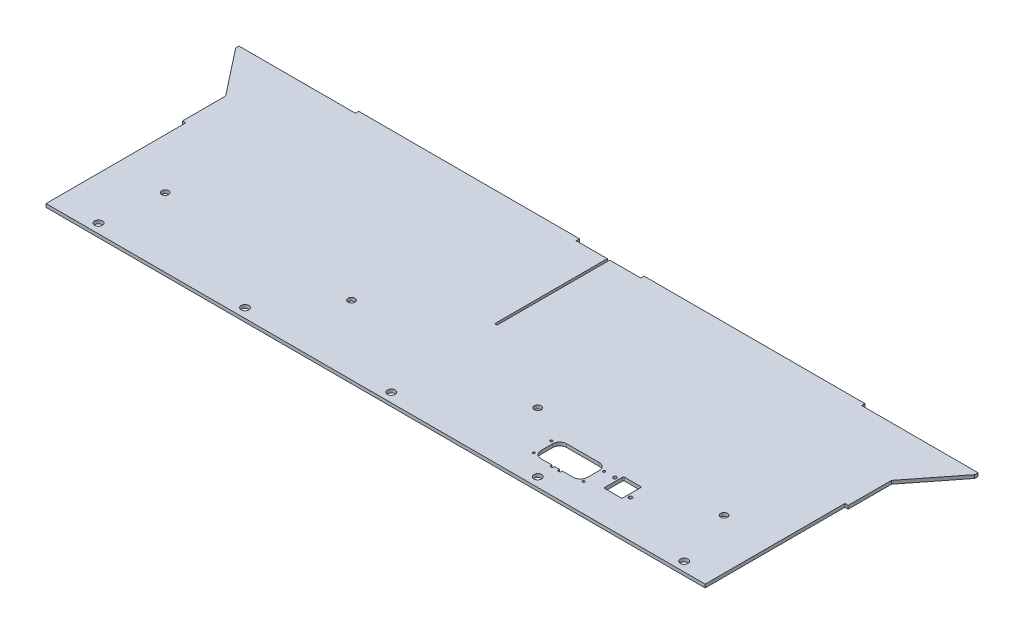
from build123d import *

# Parameters (mm, degrees)
SKETCH1_W            = 635.3556
SKETCH1_H            = 222.25
BOSS_EXTRUDE1_DEPTH  = 1.5875
BOSS_EXTRUDE3_DEPTH  = 3.175
CUT_EXTRUDE1_DEPTH   = 10
LPATTERN1_COUNT      = 5
LPATTERN1_PITCH      = 139.7
SKETCH6_W            = 3.175
SKETCH6_H            = 133.35
SKETCH6_W_2          = 2.286
SKETCH6_H_2          = 107.442
CUT_EXTRUDE2_DEPTH   = 4.175
M6_CLEARANCE_HOLE1_D = 6.6
LPATTERN2_COUNT      = 4
LPATTERN2_PITCH      = 177.8
SKETCH12_W           = 210.6549
SKETCH12_H           = 3.175
BOSS_EXTRUDE4_DEPTH  = 3.175
CUT_EXTRUDE3_DEPTH   = 4.175


with BuildPart() as part:
    # Sketch1 → Boss-Extrude1 (new body, symmetric)
    with BuildSketch(Plane(origin=(0, 0, 0), x_dir=(1, 0, 0), z_dir=(0, 1, 0))):
        Rectangle(SKETCH1_W, SKETCH1_H)
    extrude(amount=BOSS_EXTRUDE1_DEPTH, both=True)

    # Sketch3 → Boss-Extrude3 (add)
    with BuildSketch(Plane(origin=(0, 1.5875, 0), x_dir=(1, 0, 0), z_dir=(0, 1, 0))):
        Polygon((-317.6778, 63.5), (-317.6778, 111.125), (-352.6028, 111.125), (-352.6028, 107.95), align=None)
    boss_extrude3 = extrude(amount=-BOSS_EXTRUDE3_DEPTH)

    # Mirror1: Boss-Extrude3 across plane
    add(boss_extrude3.mirror(Plane(origin=(0, 0, 0), x_dir=(0, 0, 1), z_dir=(1, 0, 0))))

    # Sketch4 → Cut-Extrude1 (cut)
    with BuildSketch(Plane(origin=(0, 1.5875, 0), x_dir=(1, 0, 0), z_dir=(0, 1, 0))):
        with BuildLine():
            ThreePointArc((-276.9028, -102.235), (-275.826417421, -104.833617421), (-273.2278, -105.91))
            Line((-273.2278, -105.91), (-273.2278, -102.235))
            Line((-273.2278, -102.235), (-276.9028, -102.235))
        make_face()
        with BuildLine():
            Line((-273.2278, -102.235), (-273.2278, -105.91))
            ThreePointArc((-273.2278, -105.91), (-270.629182579, -104.833617421), (-269.5528, -102.235))
            ThreePointArc((-269.5528, -102.235), (-273.2278, -98.56), (-276.9028, -102.235))
            Line((-276.9028, -102.235), (-273.2278, -102.235))
        make_face()
    cut_extrude1 = extrude(amount=-CUT_EXTRUDE1_DEPTH, mode=Mode.SUBTRACT)

    # LPattern1: Cut-Extrude1 ×5
    with Locations(*[(i * LPATTERN1_PITCH, 0, 0) for i in range(1, LPATTERN1_COUNT)]):
        add(cut_extrude1, mode=Mode.SUBTRACT)

    # Sketch6 → Cut-Extrude2 (cut, through all)
    with BuildSketch(Plane(origin=(0, 1.5875, 0), x_dir=(1, 0, 0), z_dir=(0, 1, 0))):
        with Locations((316.0903, -44.45)):
            Rectangle(SKETCH6_W, SKETCH6_H)
        with Locations((-316.0903, -44.45)):
            Rectangle(SKETCH6_W, SKETCH6_H)
        with Locations((0, 57.404)):
            Rectangle(SKETCH6_W_2, SKETCH6_H_2)
    extrude(amount=-CUT_EXTRUDE2_DEPTH, mode=Mode.SUBTRACT)

    # M6 Clearance Hole1 (through all)
    with Locations(Plane(origin=(0, 1.5875, 0), x_dir=(1, 0, 0), z_dir=(0, 1, 0))):
        with Locations((266.7, -45.2374)):
            m6_clearance_hole1 = Hole(M6_CLEARANCE_HOLE1_D / 2)

    # LPattern2: M6 Clearance Hole1 ×4
    with Locations(*[(-i * LPATTERN2_PITCH, 0, 0) for i in range(1, LPATTERN2_COUNT)]):
        add(m6_clearance_hole1, mode=Mode.SUBTRACT)

    # Sketch12 → Boss-Extrude4 (add)
    with BuildSketch(Plane(origin=(0, 0, -111.125), x_dir=(-1, 0, 0), z_dir=(0, 0, -1))):
        with Locations((-136.15035, 0)):
            Rectangle(SKETCH12_W, SKETCH12_H)
        with Locations((136.15035, 0)):
            Rectangle(SKETCH12_W, SKETCH12_H)
    extrude(amount=BOSS_EXTRUDE4_DEPTH)

    # Sketch13 → Cut-Extrude3 (cut, through all)
    with BuildSketch(Plane(origin=(0, 1.5875, 0), x_dir=(1, 0, 0), z_dir=(0, 1, 0))):
        with BuildLine():
            add(Edge.make_bspline(
                [(187.864233968, -80.025396339), (189.329368232, -80.025396339), (191.127179802, -77.455295235), (195.339233968, -79.347764363)],
                knots=[1, 1, 1, 1, 3.549888024, 3.549888024, 3.549888024, 3.549888024], degree=3))
            Line((187.864233968, -80.025396339), (194.052572976, -80.025396339))
            add(Edge.make_bspline(
                [(194.052572976, -80.025396339), (194.505115843, -79.75389316), (194.933382129, -79.530112938), (195.339233968, -79.347764363)],
                knots=[-2.795582096, -2.795582096, -2.795582096, -2.795582096, -2.549888024, -2.549888024, -2.549888024, -2.549888024], degree=3))
        make_face()
        with BuildLine():
            add(Edge.make_bspline(
                [(172.699220274, -84.2845266), (172.696730983, -84.975084699), (172.146526339, -85.612330075), (171.260043393, -85.306178116)],
                knots=[0.001799128, 0.001799128, 0.001799128, 0.001799128, 0.583907467, 0.583907467, 0.583907467, 0.583907467], degree=3, weights=[0.996408218, 0.609732375, 0.448956611, 0.514080926]))
            add(Edge.make_bspline(
                [(172.699220274, -84.2845266), (172.233117294, -84.619527082), (171.753512925, -84.960041697), (171.260043393, -85.306178116)],
                knots=[5.458035513, 5.458035513, 5.458035513, 5.458035513, 5.553043212, 5.553043212, 5.553043212, 5.553043212], degree=3))
        make_face()
        with BuildLine():
            add(Edge.make_bspline(
                [(172.699220274, -84.2845266), (172.233117294, -84.619527082), (171.753512925, -84.960041697), (171.260043393, -85.306178116)],
                knots=[5.458035513, 5.458035513, 5.458035513, 5.458035513, 5.553043212, 5.553043212, 5.553043212, 5.553043212], degree=3))
            add(Edge.make_bspline(
                [(172.699227323, -84.280615468), (172.699227323, -84.2819184), (172.699224976, -84.283222113), (172.699220274, -84.2845266)],
                knots=[0, 0, 0, 0, 0.001799128, 0.001799128, 0.001799128, 0.001799128], degree=3, weights=[1, 0.998800581, 0.99760332, 0.996408218]))
            add(Edge.make_bspline(
                [(170.529227323, -84.280615468), (170.529227323, -82.110615468), (172.699227323, -82.110615468), (172.699227323, -84.280615468)],
                knots=[0, 0, 0, 0, 1, 1, 1, 1], degree=3, weights=[1, 0.333333333, 0.333333333, 1]))
            add(Edge.make_bspline(
                [(171.260043393, -85.306178116), (170.752605364, -85.130931488), (170.529227323, -84.697127405), (170.529227323, -84.280615468)],
                knots=[0.583907467, 0.583907467, 0.583907467, 0.583907467, 1, 1, 1, 1], degree=3, weights=[0.514080926, 0.560631953, 0.722604978, 1]))
        make_face()
        with BuildLine():
            add(Edge.make_bspline(
                [(181.739234014, -66.150396507), (181.739234014, -67.664096491), (183.22321105, -68.736498813), (184.551445026, -67.194687875)],
                knots=[0, 0, 0, 0, 0.364606415, 0.364606415, 0.364606415, 0.364606415], degree=3, weights=[1, 0.513858114, 0.382217128, 0.605077042]))
            add(Edge.make_bspline(
                [(182.357862006, -64.886707866), (183.199836269, -65.706024515), (183.926405101, -66.473982103), (184.551445026, -67.194687875)],
                knots=[-3.591687883, -3.591687883, -3.591687883, -3.591687883, -3.27186619, -3.27186619, -3.27186619, -3.27186619], degree=3))
            add(Edge.make_bspline(
                [(182.357862006, -64.886707866), (181.921014319, -65.22596081), (181.739234014, -65.701474289), (181.739234014, -66.150396507)],
                knots=[0.83567377, 0.83567377, 0.83567377, 0.83567377, 1, 1, 1, 1], degree=3, weights=[0.558719959, 0.633805013, 0.78089836, 1]))
        make_face()
        with BuildLine():
            add(Edge.make_bspline(
                [(182.357862006, -64.886707866), (183.199836269, -65.706024515), (183.926405101, -66.473982103), (184.551445026, -67.194687875)],
                knots=[-3.591687883, -3.591687883, -3.591687883, -3.591687883, -3.27186619, -3.27186619, -3.27186619, -3.27186619], degree=3))
            add(Edge.make_bspline(
                [(184.551445026, -67.194687875), (184.825523373, -66.876538362), (184.939234014, -66.502865553), (184.939234014, -66.150396507), (184.939234014, -64.854128029), (183.75318586, -63.803108847), (182.357862006, -64.886707866)],
                knots=[0.364606415, 0.364606415, 0.364606415, 0.364606415, 0.5, 0.5, 0.5, 0.83567377, 0.83567377, 0.83567377, 0.83567377], degree=3, weights=[0.605077042, 0.687834234, 0.81947522, 1, 0.552434973, 0.405341626, 0.558719959]))
        make_face()
        with BuildLine():
            add(Edge.make_bspline(
                [(208.320606163, -76.414085039), (208.757453751, -76.074832094), (208.939234014, -75.599318671), (208.939234014, -75.150396507), (208.939234014, -73.636696641), (207.455257136, -72.564294316), (206.127023101, -74.106105024)],
                knots=[0.335673786, 0.335673786, 0.335673786, 0.335673786, 0.5, 0.5, 0.5, 0.8646064, 0.8646064, 0.8646064, 0.8646064], degree=3, weights=[0.55871998, 0.633805041, 0.780898381, 1, 0.513858133, 0.382217138, 0.605077016]))
            add(Edge.make_bspline(
                [(208.320606163, -76.414085039), (207.478631887, -75.594768389), (206.752063041, -74.826810798), (206.127023101, -74.106105024)],
                knots=[-3.591687913, -3.591687913, -3.591687913, -3.591687913, -3.271866223, -3.271866223, -3.271866223, -3.271866223], degree=3))
        make_face()
        with BuildLine():
            add(Edge.make_bspline(
                [(208.320606163, -76.414085039), (207.478631887, -75.594768389), (206.752063041, -74.826810798), (206.127023101, -74.106105024)],
                knots=[-3.591687913, -3.591687913, -3.591687913, -3.591687913, -3.271866223, -3.271866223, -3.271866223, -3.271866223], degree=3))
            add(Edge.make_bspline(
                [(206.127023101, -74.106105024), (205.852944683, -74.424254558), (205.739234014, -74.797927416), (205.739234014, -75.150396507)],
                knots=[0.8646064, 0.8646064, 0.8646064, 0.8646064, 1, 1, 1, 1], degree=3, weights=[0.605077016, 0.687834206, 0.8194752, 1]))
            add(Edge.make_bspline(
                [(205.739234014, -75.150396507), (205.739234014, -76.446665096), (206.925282318, -77.497684302), (208.320606163, -76.414085039)],
                knots=[0, 0, 0, 0, 0.335673786, 0.335673786, 0.335673786, 0.335673786], degree=3, weights=[1, 0.552434953, 0.405341613, 0.55871998]))
        make_face()
        with BuildLine():
            add(Edge.make_bspline(
                [(186.714233968, -78.875396339), (186.714233968, -79.019043261), (186.763644326, -79.299941363), (187.025758436, -79.71387187), (187.439688944, -79.975985981), (187.720587046, -80.025396339), (187.864233968, -80.025396339)],
                knots=[0, 0, 0, 0, 0.25, 0.5, 0.75, 1, 1, 1, 1], degree=3))
            add(Edge.make_bspline(
                [(187.864233968, -80.025396339), (189.329368232, -80.025396339), (191.127179802, -77.455295235), (195.339233968, -79.347764363)],
                knots=[1, 1, 1, 1, 3.549888024, 3.549888024, 3.549888024, 3.549888024], degree=3))
            add(Edge.make_bspline(
                [(195.339233968, -79.347764363), (199.551288134, -77.455295235), (201.349099704, -80.025396339), (202.814233968, -80.025396339)],
                knots=[-2.549888024, -2.549888024, -2.549888024, -2.549888024, 0, 0, 0, 0], degree=3))
            add(Edge.make_bspline(
                [(202.814233968, -80.025396339), (202.95788089, -80.025396339), (203.238778991, -79.975985981), (203.652709499, -79.71387187), (203.914823609, -79.299941363), (203.964233968, -79.019043261), (203.964233968, -78.875396339)],
                knots=[0, 0, 0, 0, 0.25, 0.5, 0.75, 1, 1, 1, 1], degree=3))
            add(Edge.make_bspline(
                [(203.964233968, -78.875396339), (203.964233968, -77.326116927), (201.0904451, -75.40485046), (203.658155381, -70.650396339)],
                knots=[1, 1, 1, 1, 3.696332423, 3.696332423, 3.696332423, 3.696332423], degree=3))
            add(Edge.make_bspline(
                [(203.658155381, -70.650396339), (201.0904451, -65.895942219), (203.964233968, -63.974675752), (203.964233968, -62.425396339)],
                knots=[-2.696332423, -2.696332423, -2.696332423, -2.696332423, 0, 0, 0, 0], degree=3))
            add(Edge.make_bspline(
                [(203.964233968, -62.425396339), (203.964233968, -62.281749417), (203.914823609, -62.000851316), (203.652709499, -61.586920808), (203.238778991, -61.324806697), (202.95788089, -61.275396339), (202.814233968, -61.275396339)],
                knots=[0, 0, 0, 0, 0.25, 0.5, 0.75, 1, 1, 1, 1], degree=3))
            add(Edge.make_bspline(
                [(202.814233968, -61.275396339), (201.349099704, -61.275396339), (199.551288134, -63.845497444), (195.339233968, -61.953028316)],
                knots=[1, 1, 1, 1, 3.549888024, 3.549888024, 3.549888024, 3.549888024], degree=3))
            add(Edge.make_bspline(
                [(195.339233968, -61.953028316), (191.127179802, -63.845497444), (189.329368232, -61.275396339), (187.864233968, -61.275396339)],
                knots=[-2.549888024, -2.549888024, -2.549888024, -2.549888024, 0, 0, 0, 0], degree=3))
            add(Edge.make_bspline(
                [(187.864233968, -61.275396339), (187.720587046, -61.275396339), (187.439688944, -61.324806697), (187.025758436, -61.586920808), (186.763644326, -62.000851316), (186.714233968, -62.281749417), (186.714233968, -62.425396339)],
                knots=[0, 0, 0, 0, 0.25, 0.5, 0.75, 1, 1, 1, 1], degree=3))
            add(Edge.make_bspline(
                [(186.714233968, -62.425396339), (186.714233968, -63.974675752), (189.588022835, -65.895942219), (187.020312555, -70.650396339)],
                knots=[1, 1, 1, 1, 3.696332423, 3.696332423, 3.696332423, 3.696332423], degree=3))
            add(Edge.make_bspline(
                [(187.020312555, -70.650396339), (189.588022835, -75.40485046), (186.714233968, -77.326116927), (186.714233968, -78.875396339)],
                knots=[-2.696332423, -2.696332423, -2.696332423, -2.696332423, 0, 0, 0, 0], degree=3))
        make_face()
        with BuildLine():
            add(Edge.make_bspline(
                [(194.052572976, -80.025396339), (194.505115843, -79.75389316), (194.933382129, -79.530112938), (195.339233968, -79.347764363)],
                knots=[-2.795582096, -2.795582096, -2.795582096, -2.795582096, -2.549888024, -2.549888024, -2.549888024, -2.549888024], degree=3))
            Line((194.052572976, -80.025396339), (196.62589496, -80.025396339))
            add(Edge.make_bspline(
                [(195.339233968, -79.347764363), (195.745085806, -79.530112938), (196.173352092, -79.75389316), (196.62589496, -80.025396339)],
                knots=[3.549888024, 3.549888024, 3.549888024, 3.549888024, 3.795582096, 3.795582096, 3.795582096, 3.795582096], degree=3))
        make_face()
        with BuildLine():
            Line((186.714233968, -71.187057331), (186.714233968, -78.875396339))
            add(Edge.make_bspline(
                [(187.020312555, -70.650396339), (189.588022835, -75.40485046), (186.714233968, -77.326116927), (186.714233968, -78.875396339)],
                knots=[-2.696332423, -2.696332423, -2.696332423, -2.696332423, 0, 0, 0, 0], degree=3))
            add(Edge.make_bspline(
                [(187.020312555, -70.650396339), (186.925797352, -70.825403699), (186.823909393, -71.00424978), (186.714233968, -71.187057331)],
                knots=[3.696332423, 3.696332423, 3.696332423, 3.696332423, 3.795582096, 3.795582096, 3.795582096, 3.795582096], degree=3))
        make_face()
        with BuildLine():
            add(Edge.make_bspline(
                [(195.339233968, -79.347764363), (199.551288134, -77.455295235), (201.349099704, -80.025396339), (202.814233968, -80.025396339)],
                knots=[-2.549888024, -2.549888024, -2.549888024, -2.549888024, 0, 0, 0, 0], degree=3))
            add(Edge.make_bspline(
                [(195.339233968, -79.347764363), (195.745085806, -79.530112938), (196.173352092, -79.75389316), (196.62589496, -80.025396339)],
                knots=[3.549888024, 3.549888024, 3.549888024, 3.549888024, 3.795582096, 3.795582096, 3.795582096, 3.795582096], degree=3))
            Line((196.62589496, -80.025396339), (202.814233968, -80.025396339))
        make_face()
        with BuildLine():
            Line((186.714233968, -70.113735347), (186.714233968, -71.187057331))
            add(Edge.make_bspline(
                [(187.020312555, -70.650396339), (186.925797352, -70.825403699), (186.823909393, -71.00424978), (186.714233968, -71.187057331)],
                knots=[3.696332423, 3.696332423, 3.696332423, 3.696332423, 3.795582096, 3.795582096, 3.795582096, 3.795582096], degree=3))
            add(Edge.make_bspline(
                [(186.714233968, -70.113735347), (186.823909393, -70.296542898), (186.925797352, -70.47538898), (187.020312555, -70.650396339)],
                knots=[-2.795582096, -2.795582096, -2.795582096, -2.795582096, -2.696332423, -2.696332423, -2.696332423, -2.696332423], degree=3))
        make_face()
        with BuildLine():
            add(Edge.make_bspline(
                [(186.714233968, -70.113735347), (186.823909393, -70.296542898), (186.925797352, -70.47538898), (187.020312555, -70.650396339)],
                knots=[-2.795582096, -2.795582096, -2.795582096, -2.795582096, -2.696332423, -2.696332423, -2.696332423, -2.696332423], degree=3))
            add(Edge.make_bspline(
                [(186.714233968, -62.425396339), (186.714233968, -63.974675752), (189.588022835, -65.895942219), (187.020312555, -70.650396339)],
                knots=[1, 1, 1, 1, 3.696332423, 3.696332423, 3.696332423, 3.696332423], degree=3))
            Line((186.714233968, -62.425396339), (186.714233968, -70.113735347))
        make_face()
        with BuildLine():
            add(Edge.make_bspline(
                [(203.964233968, -78.875396339), (203.964233968, -77.326116927), (201.0904451, -75.40485046), (203.658155381, -70.650396339)],
                knots=[1, 1, 1, 1, 3.696332423, 3.696332423, 3.696332423, 3.696332423], degree=3))
            Line((203.964233968, -78.875396339), (203.964233968, -71.187057331))
            add(Edge.make_bspline(
                [(203.964233968, -71.187057331), (203.854558543, -71.00424978), (203.752670584, -70.825403698), (203.658155381, -70.650396339)],
                knots=[-2.795582096, -2.795582096, -2.795582096, -2.795582096, -2.696332423, -2.696332423, -2.696332423, -2.696332423], degree=3))
        make_face()
        with BuildLine():
            Line((194.052572976, -61.275396339), (187.864233968, -61.275396339))
            add(Edge.make_bspline(
                [(195.339233968, -61.953028316), (191.127179802, -63.845497444), (189.329368232, -61.275396339), (187.864233968, -61.275396339)],
                knots=[-2.549888024, -2.549888024, -2.549888024, -2.549888024, 0, 0, 0, 0], degree=3))
            add(Edge.make_bspline(
                [(195.339233968, -61.953028316), (194.93338213, -61.770679741), (194.505115843, -61.546899518), (194.052572976, -61.275396339)],
                knots=[3.549888024, 3.549888024, 3.549888024, 3.549888024, 3.795582096, 3.795582096, 3.795582096, 3.795582096], degree=3))
        make_face()
        with BuildLine():
            add(Edge.make_bspline(
                [(203.964233968, -71.187057331), (203.854558543, -71.00424978), (203.752670584, -70.825403698), (203.658155381, -70.650396339)],
                knots=[-2.795582096, -2.795582096, -2.795582096, -2.795582096, -2.696332423, -2.696332423, -2.696332423, -2.696332423], degree=3))
            Line((203.964233968, -71.187057331), (203.964233968, -70.113735347))
            add(Edge.make_bspline(
                [(203.658155381, -70.650396339), (203.752670584, -70.475388979), (203.854558543, -70.296542898), (203.964233968, -70.113735347)],
                knots=[3.696332423, 3.696332423, 3.696332423, 3.696332423, 3.795582096, 3.795582096, 3.795582096, 3.795582096], degree=3))
        make_face()
        with BuildLine():
            add(Edge.make_bspline(
                [(203.658155381, -70.650396339), (201.0904451, -65.895942219), (203.964233968, -63.974675752), (203.964233968, -62.425396339)],
                knots=[-2.696332423, -2.696332423, -2.696332423, -2.696332423, 0, 0, 0, 0], degree=3))
            add(Edge.make_bspline(
                [(203.658155381, -70.650396339), (203.752670584, -70.475388979), (203.854558543, -70.296542898), (203.964233968, -70.113735347)],
                knots=[3.696332423, 3.696332423, 3.696332423, 3.696332423, 3.795582096, 3.795582096, 3.795582096, 3.795582096], degree=3))
            Line((203.964233968, -70.113735347), (203.964233968, -62.425396339))
        make_face()
        with BuildLine():
            Line((196.62589496, -61.275396339), (194.052572976, -61.275396339))
            add(Edge.make_bspline(
                [(195.339233968, -61.953028316), (194.93338213, -61.770679741), (194.505115843, -61.546899518), (194.052572976, -61.275396339)],
                knots=[3.549888024, 3.549888024, 3.549888024, 3.549888024, 3.795582096, 3.795582096, 3.795582096, 3.795582096], degree=3))
            add(Edge.make_bspline(
                [(196.62589496, -61.275396339), (196.173352092, -61.546899518), (195.745085806, -61.770679741), (195.339233968, -61.953028316)],
                knots=[-2.795582096, -2.795582096, -2.795582096, -2.795582096, -2.549888024, -2.549888024, -2.549888024, -2.549888024], degree=3))
        make_face()
        with BuildLine():
            add(Edge.make_bspline(
                [(196.62589496, -61.275396339), (196.173352092, -61.546899518), (195.745085806, -61.770679741), (195.339233968, -61.953028316)],
                knots=[-2.795582096, -2.795582096, -2.795582096, -2.795582096, -2.549888024, -2.549888024, -2.549888024, -2.549888024], degree=3))
            add(Edge.make_bspline(
                [(202.814233968, -61.275396339), (201.349099704, -61.275396339), (199.551288134, -63.845497444), (195.339233968, -61.953028316)],
                knots=[1, 1, 1, 1, 3.549888024, 3.549888024, 3.549888024, 3.549888024], degree=3))
            Line((202.814233968, -61.275396339), (196.62589496, -61.275396339))
        make_face()
        with BuildLine():
            Line((143.131038887, -87.780614796), (145.497415414, -87.780614796))
            Line((145.497415414, -87.780614796), (145.672392695, -85.780614626))
            Line((145.672392695, -85.780614626), (150.156061514, -85.780614626))
            Line((150.156061514, -85.780614626), (150.331038887, -87.780614796))
            Line((150.331038887, -87.780614796), (152.697415414, -87.780614796))
            Line((152.697415414, -87.780614796), (152.872392695, -85.780614626))
            Line((152.872392695, -85.780614626), (163.414227094, -85.780614626))
            ThreePointArc((163.414227094, -85.780614626), (168.151842527, -83.81823006), (170.114227094, -79.080614626))
            Line((170.114227094, -79.080614626), (170.114227094, -67.880614626))
            ThreePointArc((170.114227094, -67.880614626), (168.151842527, -63.142999192), (163.414227094, -61.180614626))
            Line((163.414227094, -61.180614626), (132.414227094, -61.180614626))
            ThreePointArc((132.414227094, -61.180614626), (127.67661166, -63.142999192), (125.714227094, -67.880614626))
            Line((125.714227094, -67.880614626), (125.714227094, -79.080614626))
            ThreePointArc((125.714227094, -79.080614626), (127.67661166, -83.81823006), (132.414227094, -85.780614626))
            Line((132.414227094, -85.780614626), (142.956061514, -85.780614626))
            Line((142.956061514, -85.780614626), (143.131038887, -87.780614796))
        make_face()
        with BuildLine():
            add(Edge.make_bspline(
                [(121.629227323, -66.180615468), (121.629227323, -64.010615468), (123.799227323, -64.010615468), (123.799227323, -66.180615468)],
                knots=[0, 0, 0, 0, 1, 1, 1, 1], degree=3, weights=[1, 0.333333333, 0.333333333, 1]))
            add(Edge.make_bspline(
                [(123.799227323, -66.180615468), (123.799227323, -68.350615468), (121.629227323, -68.350615468), (121.629227323, -66.180615468)],
                knots=[0, 0, 0, 0, 1, 1, 1, 1], degree=3, weights=[1, 0.333333333, 0.333333333, 1]))
        make_face()
        with BuildLine():
            add(Edge.make_bspline(
                [(123.129227323, -84.280615468), (123.129227323, -82.110615468), (125.299227323, -82.110615468), (125.299227323, -84.280615468)],
                knots=[0, 0, 0, 0, 1, 1, 1, 1], degree=3, weights=[1, 0.333333333, 0.333333333, 1]))
            add(Edge.make_bspline(
                [(125.299227323, -84.280615468), (125.299227323, -86.450615468), (123.129227323, -86.450615468), (123.129227323, -84.280615468)],
                knots=[0, 0, 0, 0, 1, 1, 1, 1], degree=3, weights=[1, 0.333333333, 0.333333333, 1]))
        make_face()
        with BuildLine():
            add(Edge.make_bspline(
                [(172.029227323, -66.180615468), (172.029227323, -64.010615468), (174.199227323, -64.010615468), (174.199227323, -66.180615468)],
                knots=[0, 0, 0, 0, 1, 1, 1, 1], degree=3, weights=[1, 0.333333333, 0.333333333, 1]))
            add(Edge.make_bspline(
                [(174.199227323, -66.180615468), (174.199227323, -68.350615468), (172.029227323, -68.350615468), (172.029227323, -66.180615468)],
                knots=[0, 0, 0, 0, 1, 1, 1, 1], degree=3, weights=[1, 0.333333333, 0.333333333, 1]))
        make_face()
    extrude(amount=-CUT_EXTRUDE3_DEPTH, mode=Mode.SUBTRACT)


solid = part.part
